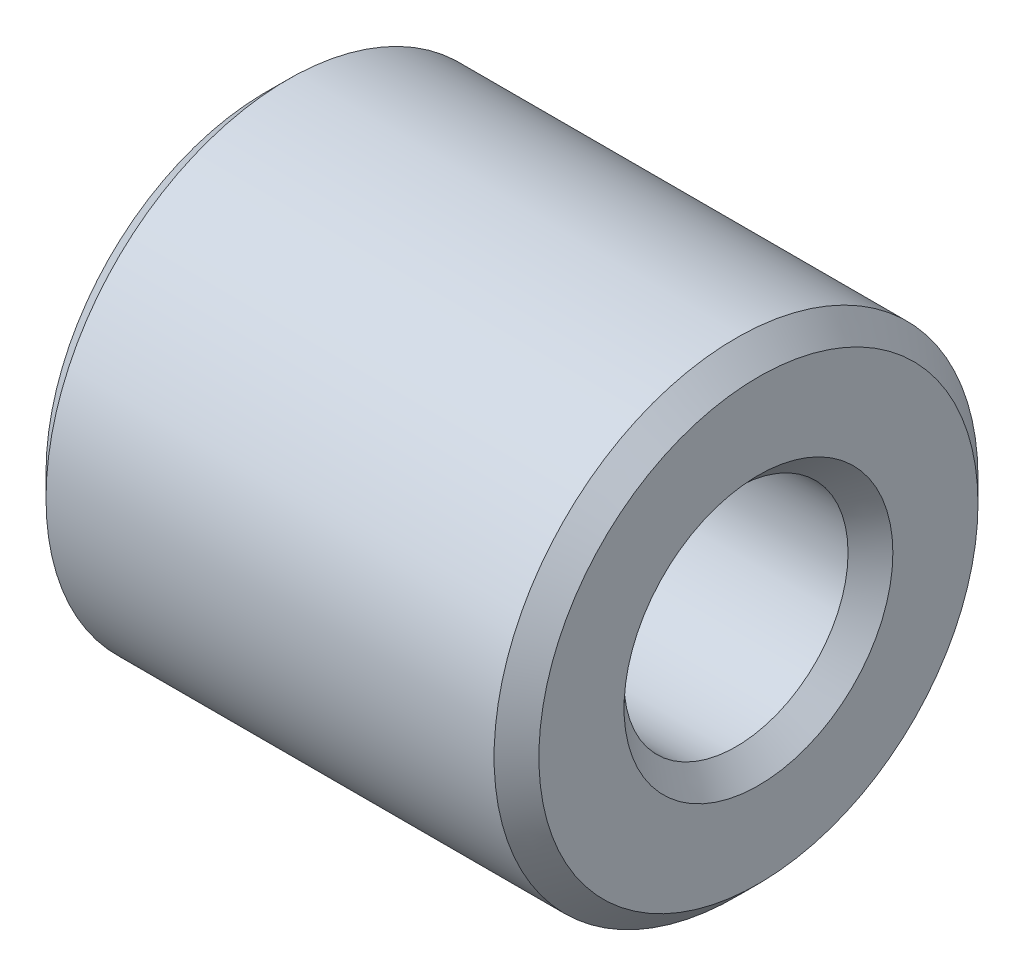
from build123d import *

# Parameters (mm, degrees)
SKETCH1_W          = 11
SKETCH1_H          = 2.9
SKETCH2_R          = 1.5
CUT_EXTRUDE1_DEPTH = 10
CHAMFER1_SIZE      = 0.5


with BuildPart() as part:
    # Sketch1 → Revolve1 (revolve)
    with BuildSketch(Plane.XY):
        with Locations((0, 3.95)):
            Rectangle(SKETCH1_W, SKETCH1_H)
    revolve(axis=Axis((0, 0, 0), (-1, 0, 0)))

    # Sketch2 → Cut-Extrude1 (cut)
    with BuildSketch(Plane(origin=(0, 0, 0), x_dir=(1, 0, 0), z_dir=(0, 1, 0))):
        with Locations((-2.75, 0)):
            Circle(SKETCH2_R)
    extrude(amount=-CUT_EXTRUDE1_DEPTH, mode=Mode.SUBTRACT)

    # Chamfer1
    chamfer1_edges = [part.edges().sort_by_distance(p)[0] for p in [
        (-5.5, -5.4, 0),
        (5.5, -5.4, 0),
        (5.5, -2.5, 0),
        (-5.5, -2.5, 0),
    ]]
    chamfer(chamfer1_edges, length=CHAMFER1_SIZE)


solid = part.part
